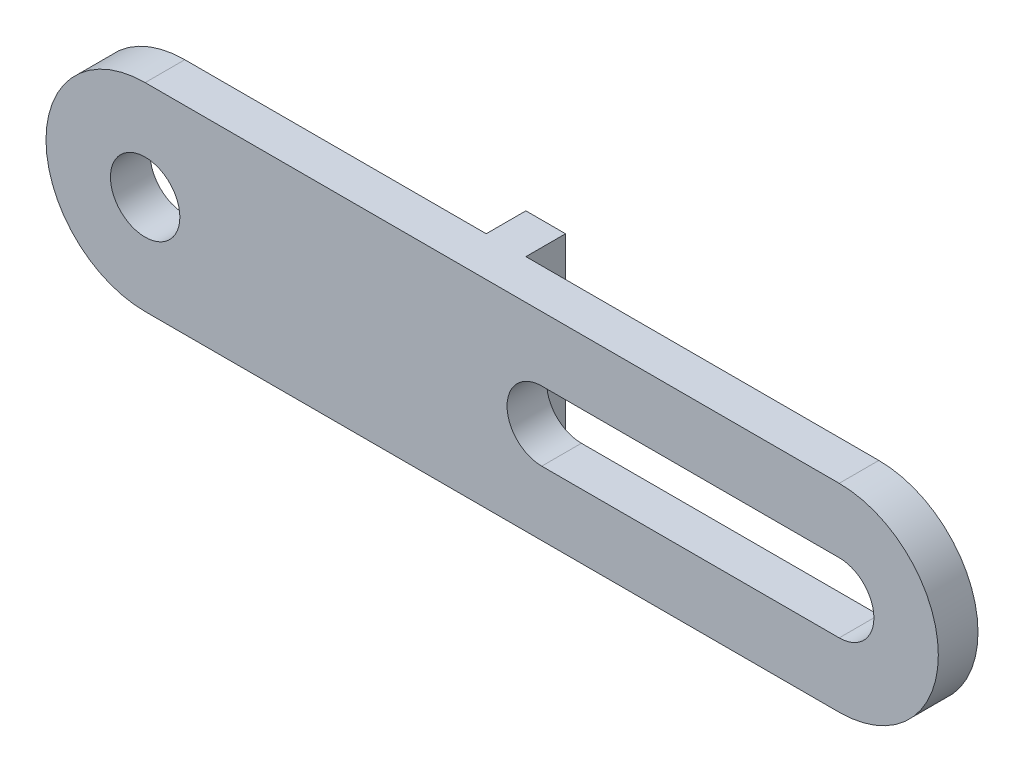
from build123d import *

# Parameters (mm, degrees)
ESBO_O1_R                = 1.75
RESSALTO_EXTRUS_O1_DEPTH = 2
ESBO_O2_W                = 2
ESBO_O2_H                = 10
RESSALTO_EXTRUS_O2_DEPTH = 2


with BuildPart() as part:
    # Esboço1 → Ressalto-extrusão1 (new body)
    with BuildSketch(Plane.XY):
        with BuildLine():
            Line((0, 5), (35, 5))
            ThreePointArc((35, 5), (40, 0), (35, -5))
            Line((35, -5), (0, -5))
            ThreePointArc((0, -5), (-5, 0), (0, 5))
        make_face()
        Circle(ESBO_O1_R, mode=Mode.SUBTRACT)
        with BuildLine():
            Line((20, 1.75), (35, 1.75))
            ThreePointArc((35, 1.75), (36.75, 0), (35, -1.75))
            Line((35, -1.75), (20, -1.75))
            ThreePointArc((20, -1.75), (18.25, 0), (20, 1.75))
        make_face(mode=Mode.SUBTRACT)
    extrude(amount=RESSALTO_EXTRUS_O1_DEPTH)

    # Esboço2 → Ressalto-extrusão2 (add)
    with BuildSketch(Plane(origin=(0, 0, 0), x_dir=(-1, 0, 0), z_dir=(0, 0, -1))):
        with Locations((-16.2, 0)):
            Rectangle(ESBO_O2_W, ESBO_O2_H)
    extrude(amount=RESSALTO_EXTRUS_O2_DEPTH)


solid = part.part
